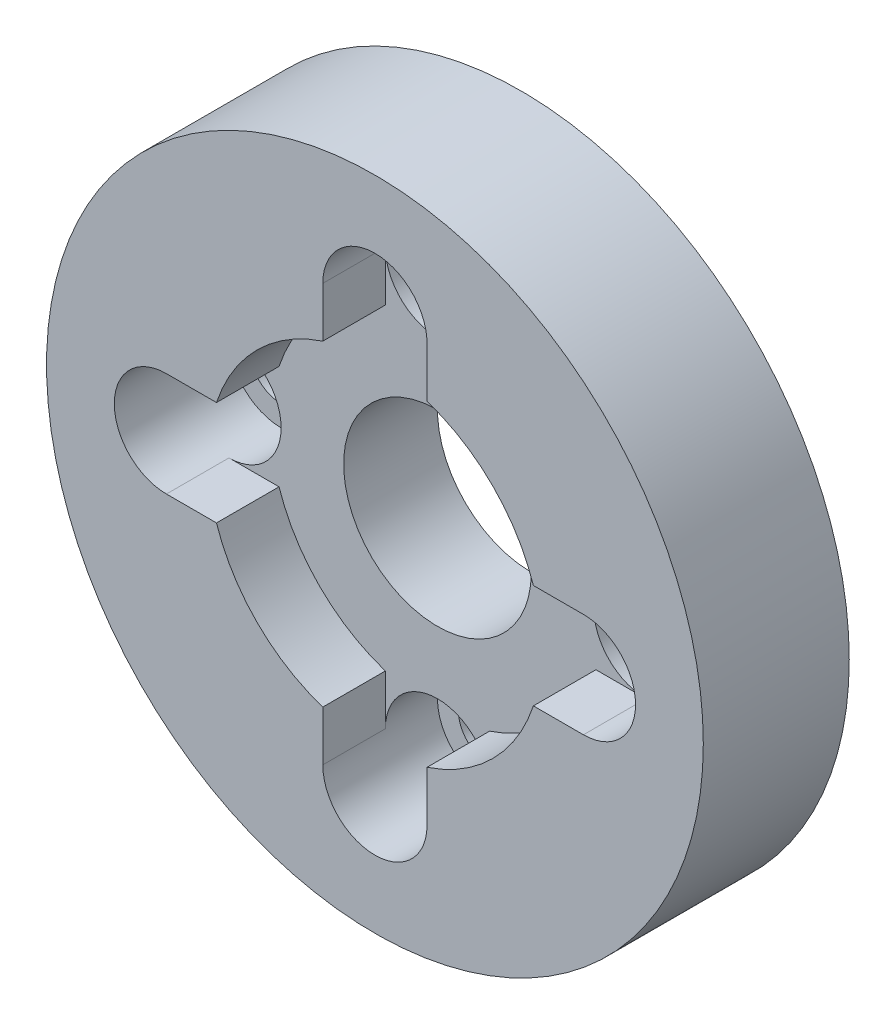
from build123d import *

# Parameters (mm, degrees)
SKETCH1_R           = 31.5
SKETCH1_R_2         = 16
BOSS_EXTRUDE1_DEPTH = 14
SKETCH1_3_R         = 16
SKETCH1_3_R_2       = 12.5
SKETCH1_3_R_3       = 9
BOSS_EXTRUDE2_DEPTH = 8
SKETCH1_4_R         = 12.5
SKETCH1_4_R_2       = 9
BOSS_EXTRUDE3_DEPTH = 1
SKETCH2_R           = 3
CUT_EXTRUDE1_DEPTH  = 16
CUT_EXTRUDE2_DEPTH  = 6
SKETCH2_4_R         = 5
CUT_EXTRUDE3_DEPTH  = 11


with BuildPart() as part:
    # Sketch1 → Boss-Extrude1 (new body)
    with BuildSketch(Plane.XY):
        Circle(SKETCH1_R)
        Circle(SKETCH1_R_2, mode=Mode.SUBTRACT)
    extrude(amount=BOSS_EXTRUDE1_DEPTH)

    # Sketch1_3 → Boss-Extrude2 (add)
    with BuildSketch(Plane.XY):
        Circle(SKETCH1_3_R)
        Circle(SKETCH1_3_R_2, mode=Mode.SUBTRACT)
        Circle(SKETCH1_3_R_2)
        Circle(SKETCH1_3_R_3, mode=Mode.SUBTRACT)
    extrude(amount=BOSS_EXTRUDE2_DEPTH)

    # Sketch1_4 → Boss-Extrude3 (add)
    with BuildSketch(Plane.XY):
        Circle(SKETCH1_4_R)
        Circle(SKETCH1_4_R_2, mode=Mode.SUBTRACT)
    extrude(amount=-BOSS_EXTRUDE3_DEPTH)

    # Sketch2 → Cut-Extrude1 (cut, through all)
    with BuildSketch(Plane.XY.offset(14)):
        with Locations((-20, 0)):
            Circle(SKETCH2_R)
        with Locations((0, 20)):
            Circle(SKETCH2_R)
        with Locations((20, 0)):
            Circle(SKETCH2_R)
        with Locations((0, -20)):
            Circle(SKETCH2_R)
    extrude(amount=-CUT_EXTRUDE1_DEPTH, mode=Mode.SUBTRACT)

    # Sketch2_3 → Cut-Extrude2 (cut)
    with BuildSketch(Plane.XY.offset(14)):
        with BuildLine():
            Line((-20, -5), (-15.198684154, -5))
            ThreePointArc((-15.198684154, -5), (-15.53045532, -3.847721084), (-15.775, -2.67383152))
            ThreePointArc((-15.775, -2.67383152), (-17.588481557, -4.380020411), (-20, -5))
        make_face()
        with BuildLine():
            ThreePointArc((-20, 5), (-17.588481557, 4.380020411), (-15.775, 2.67383152))
            ThreePointArc((-15.775, 2.67383152), (-15.53045532, 3.847721084), (-15.198684154, 5))
            Line((-15.198684154, 5), (-20, 5))
        make_face()
        with BuildLine():
            Line((-5, 20), (-5, 15.198684154))
            ThreePointArc((-5, 15.198684154), (-3.847721084, 15.53045532), (-2.67383152, 15.775))
            ThreePointArc((-2.67383152, 15.775), (-4.380020411, 17.588481557), (-5, 20))
        make_face()
        with BuildLine():
            Line((5, 15.198684154), (5, 20))
            ThreePointArc((5, 20), (4.380020411, 17.588481557), (2.67383152, 15.775))
            ThreePointArc((2.67383152, 15.775), (3.847721084, 15.53045532), (5, 15.198684154))
        make_face()
        with BuildLine():
            ThreePointArc((-2.67383152, -15.775), (-3.847721084, -15.53045532), (-5, -15.198684154))
            Line((-5, -15.198684154), (-5, -20))
            ThreePointArc((-5, -20), (-4.380020411, -17.588481557), (-2.67383152, -15.775))
        make_face()
        with BuildLine():
            ThreePointArc((2.67383152, -15.775), (4.380020411, -17.588481557), (5, -20))
            Line((5, -20), (5, -15.198684154))
            ThreePointArc((5, -15.198684154), (3.847721084, -15.53045532), (2.67383152, -15.775))
        make_face()
        with BuildLine():
            ThreePointArc((15.775, -2.67383152), (15.53045532, -3.847721084), (15.198684154, -5))
            Line((15.198684154, -5), (20, -5))
            ThreePointArc((20, -5), (17.588481557, -4.380020411), (15.775, -2.67383152))
        make_face()
        with BuildLine():
            Line((20, 5), (15.198684154, 5))
            ThreePointArc((15.198684154, 5), (15.53045532, 3.847721084), (15.775, 2.67383152))
            ThreePointArc((15.775, 2.67383152), (17.588481557, 4.380020411), (20, 5))
        make_face()
    extrude(amount=-CUT_EXTRUDE2_DEPTH, mode=Mode.SUBTRACT)

    # Sketch2_4 → Cut-Extrude3 (cut)
    with BuildSketch(Plane.XY.offset(14)):
        with Locations((-20, 0)):
            Circle(SKETCH2_4_R)
        with Locations((20, 0)):
            Circle(SKETCH2_4_R)
        with Locations((0, 20)):
            Circle(SKETCH2_4_R)
        with Locations((0, -20)):
            Circle(SKETCH2_4_R)
    extrude(amount=-CUT_EXTRUDE3_DEPTH, mode=Mode.SUBTRACT)


solid = part.part
